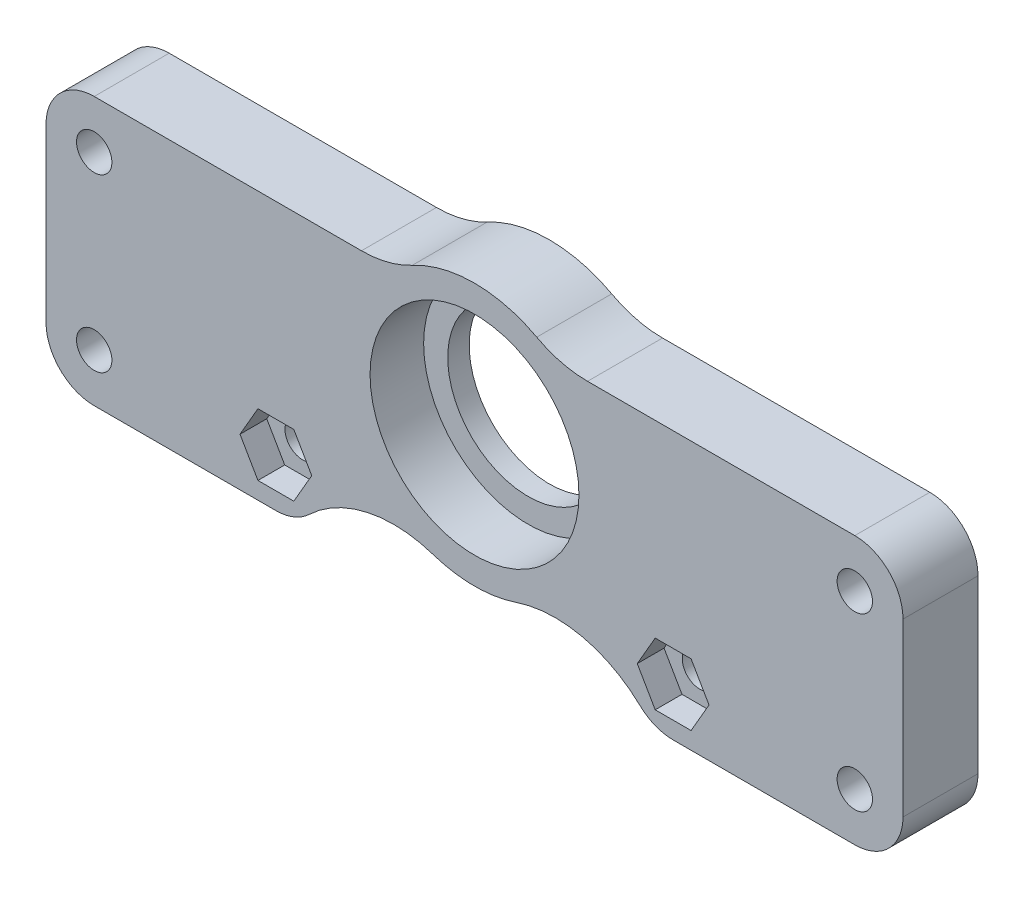
from build123d import *

# Parameters (mm, degrees)
SKETCH1_R           = 9.75
SKETCH1_R_2         = 1.65
BOSS_EXTRUDE1_DEPTH = 7
FILLET1_R           = 10
SKETCH2_R           = 9.75
SKETCH2_R_2         = 7.5
BOSS_EXTRUDE2_DEPTH = 2
CUT_EXTRUDE1_DEPTH  = 2.5
SKETCH4_R           = 2.5
SKETCH4_R_2         = 1.65
BOSS_EXTRUDE3_DEPTH = 1.5
SKETCH5_R           = 2.95
CUT_EXTRUDE2_DEPTH  = 3.2


with BuildPart() as part:
    # Sketch1 → Boss-Extrude1 (new body)
    with BuildSketch(Plane.XY):
        with BuildLine():
            Line((-35.5, 9.588593938), (-7.623737029, 9.588593938))
            ThreePointArc((-7.623737029, 9.588593938), (0, 12.25), (7.623737029, 9.588593938))
            Line((7.623737029, 9.588593938), (35.5, 9.588593938))
            ThreePointArc((35.5, 9.588593938), (38.681980515, 8.270574454), (40, 5.088593938))
            Line((40, 5.088593938), (40, -10.911406062))
            ThreePointArc((40, -10.911406062), (38.681980515, -14.093386577), (35.5, -15.411406062))
            Line((35.5, -15.411406062), (18.542115282, -15.411406062))
            ThreePointArc((18.542115282, -15.411406062), (16.87570332, -15.091486345), (15.44623271, -14.177215472))
            ThreePointArc((15.44623271, -14.177215472), (10.021005103, -11.295196388), (3.88623271, -11.617215472))
            ThreePointArc((3.88623271, -11.617215472), (0, -12.25), (-3.88623271, -11.617215472))
            ThreePointArc((-3.88623271, -11.617215472), (-10.021005103, -11.295196388), (-15.44623271, -14.177215472))
            ThreePointArc((-15.44623271, -14.177215472), (-16.87570332, -15.091486345), (-18.542115282, -15.411406062))
            Line((-18.542115282, -15.411406062), (-35.5, -15.411406062))
            ThreePointArc((-35.5, -15.411406062), (-38.681980515, -14.093386577), (-40, -10.911406062))
            Line((-40, -10.911406062), (-40, 5.088593938))
            ThreePointArc((-40, 5.088593938), (-38.681980515, 8.270574454), (-35.5, 9.588593938))
        make_face()
        Circle(SKETCH1_R, mode=Mode.SUBTRACT)
        with Locations((-35.5, 5.088593938)):
            Circle(SKETCH1_R_2, mode=Mode.SUBTRACT)
        with Locations((35.5, 5.088593938)):
            Circle(SKETCH1_R_2, mode=Mode.SUBTRACT)
        with Locations((-18.542115282, -10.911406062)):
            Circle(SKETCH1_R_2, mode=Mode.SUBTRACT)
        with Locations((-35.5, -10.911406062)):
            Circle(SKETCH1_R_2, mode=Mode.SUBTRACT)
        with Locations((18.542115282, -10.911406062)):
            Circle(SKETCH1_R_2, mode=Mode.SUBTRACT)
        with Locations((35.5, -10.911406062)):
            Circle(SKETCH1_R_2, mode=Mode.SUBTRACT)
    extrude(amount=BOSS_EXTRUDE1_DEPTH)

    # Fillet1
    fillet1_edges = [part.edges().sort_by_distance(p)[0] for p in [
        (-7.623737029, 9.588593938, 3.5),
        (7.623737029, 9.588593938, 3.5),
    ]]
    fillet(fillet1_edges, radius=FILLET1_R)

    # Sketch2 → Boss-Extrude2 (add)
    with BuildSketch(Plane.XY):
        Circle(SKETCH2_R)
        Circle(SKETCH2_R_2, mode=Mode.SUBTRACT)
    extrude(amount=BOSS_EXTRUDE2_DEPTH)

    # Sketch3 → Cut-Extrude1 (cut)
    with BuildSketch(Plane.XY.offset(7)):
        Polygon((-16.867799501, -8.011406062), (-20.216431062, -8.011406062), (-21.890746843, -10.911406062), (-20.216431062, -13.811406062), (-16.867799501, -13.811406062), (-15.19348372, -10.911406062), align=None)
        Polygon((20.216431062, -8.011406062), (16.867799501, -8.011406062), (15.19348372, -10.911406062), (16.867799501, -13.811406062), (20.216431062, -13.811406062), (21.890746843, -10.911406062), align=None)
    extrude(amount=-CUT_EXTRUDE1_DEPTH, mode=Mode.SUBTRACT)

    # Sketch4 → Boss-Extrude3 (add)
    with BuildSketch(Plane(origin=(0, 0, 0), x_dir=(-1, 0, 0), z_dir=(0, 0, -1))):
        with Locations((-18.542115282, -10.911406062)):
            Circle(SKETCH4_R)
        with Locations((-18.542115282, -10.911406062)):
            Circle(SKETCH4_R_2, mode=Mode.SUBTRACT)
        with Locations((18.542115282, -10.911406062)):
            Circle(SKETCH4_R)
        with Locations((18.542115282, -10.911406062)):
            Circle(SKETCH4_R_2, mode=Mode.SUBTRACT)
    extrude(amount=BOSS_EXTRUDE3_DEPTH)

    # Sketch5 → Cut-Extrude2 (cut)
    with BuildSketch(Plane(origin=(0, 0, 0), x_dir=(-1, 0, 0), z_dir=(0, 0, -1))):
        with Locations((-35.5, 5.088593938)):
            Circle(SKETCH5_R)
        with Locations((-35.5, -10.911406062)):
            Circle(SKETCH5_R)
        with Locations((35.5, 5.088593938)):
            Circle(SKETCH5_R)
        with Locations((35.5, -10.911406062)):
            Circle(SKETCH5_R)
    extrude(amount=-CUT_EXTRUDE2_DEPTH, mode=Mode.SUBTRACT)


solid = part.part
